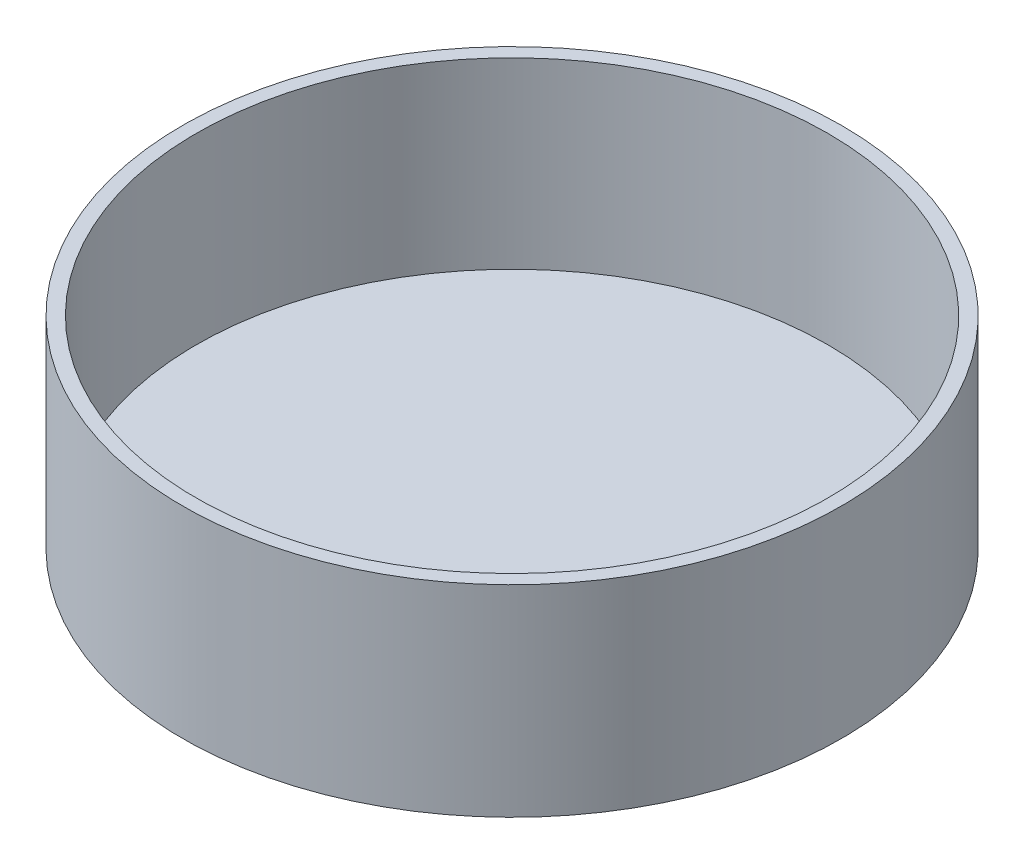
from build123d import *


with BuildPart() as part:
    # Sketch1 → Revolve1 (revolve)
    with BuildSketch(Plane(origin=(0, 0, 0), x_dir=(0, 0, -1), z_dir=(1, 0, 0)), mode=Mode.PRIVATE) as revolve1_sk:
        Polygon((0, 0), (-114.3, 0), (-114.3, 69.85), (-109.5375, 69.85), (-109.5375, 6.35), (0, 6.35), align=None)
    revolve(revolve1_sk.sketch.rotate(Axis((0, -45.633687212, 0), (0, 1, 0)), 180), axis=Axis((0, -45.633687212, 0), (0, 1, 0)))  # turned: the seam where the file's is


solid = part.part
